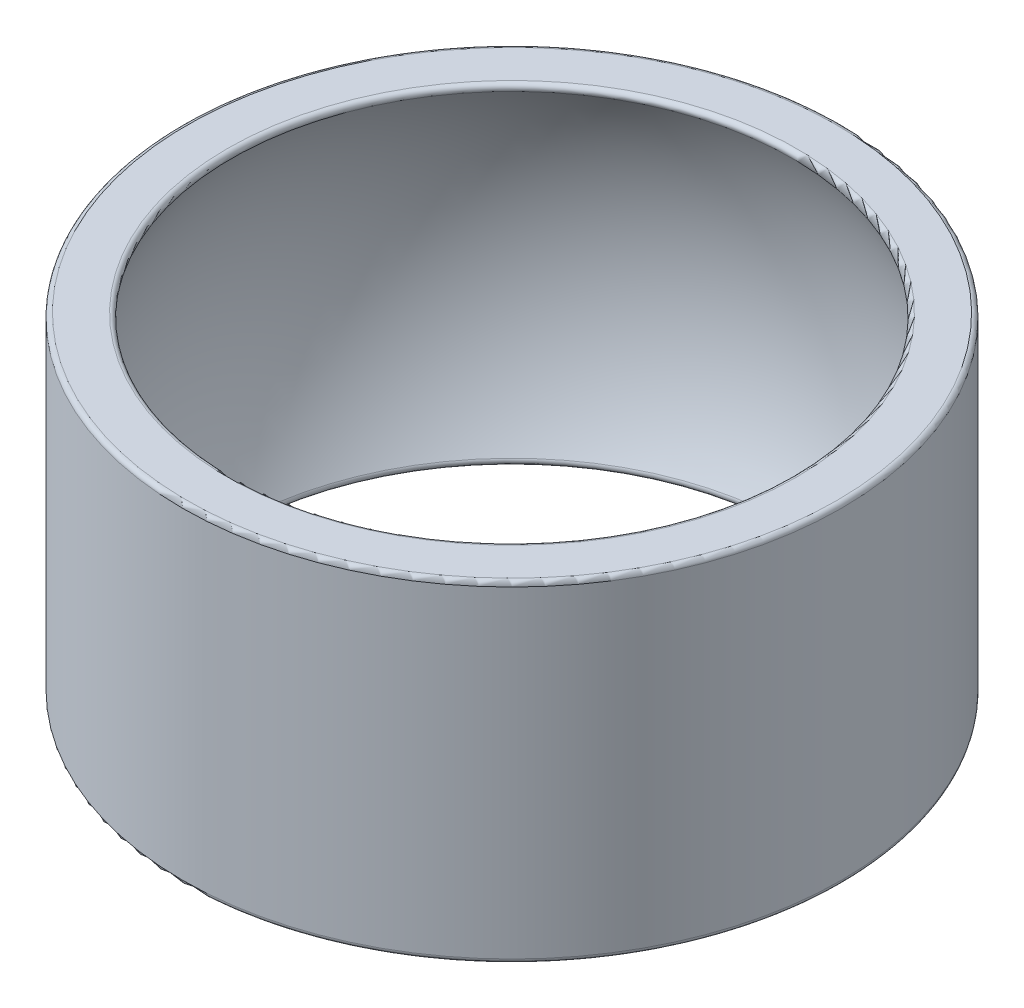
from build123d import *

# Parameters (mm, degrees)
FILLET1_R = 0.3


with BuildPart() as part:
    # Sketch1 → Revolve1 (revolve)
    with BuildSketch(Plane.XY):
        with BuildLine():
            Line((18.385609182, 11), (21.891779279, 11))
            Line((21.891779279, 11), (21.891779279, -11))
            Line((21.891779279, -11), (18.385609182, -11))
            ThreePointArc((18.385609182, -11), (21.425, 0), (18.385609182, 11))
        make_face()
    revolve(axis=Axis((0, 11, 0), (0, -1, 0)))

    # Fillet1
    fillet1_edges = [part.edges().sort_by_distance(p)[0] for p in [
        (-21.891779279, -11, 0),
        (-18.385609182, -11, 0),
        (-18.385609182, 11, 0),
        (-21.891779279, 11, 0),
    ]]
    fillet(fillet1_edges, radius=FILLET1_R)


solid = part.part
